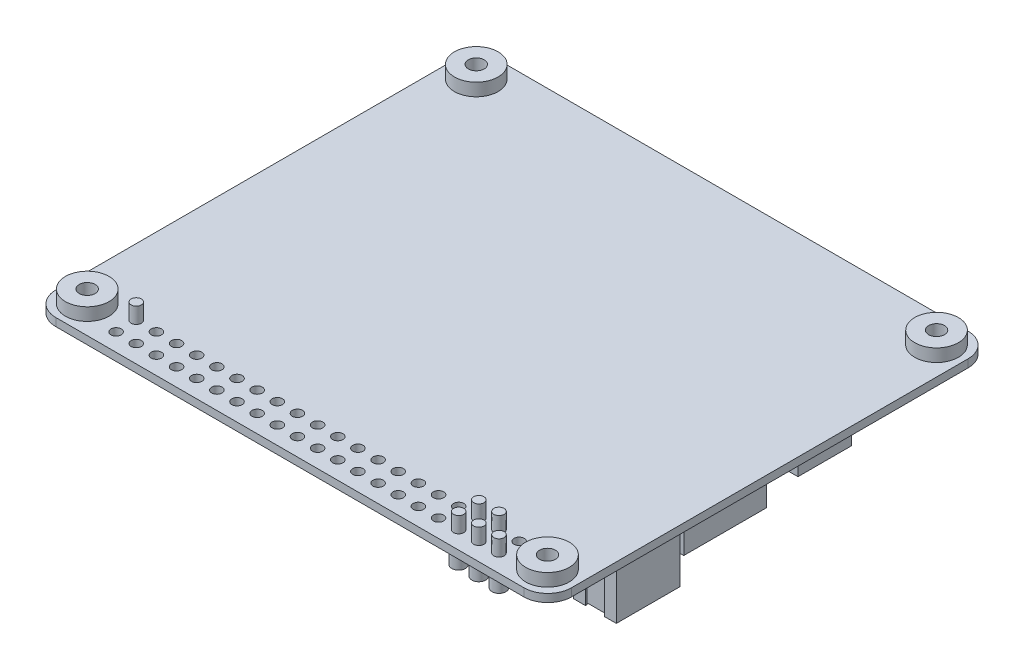
from build123d import *

# Parameters (mm, degrees)
SKETCH_1_W          = 65
SKETCH_1_H          = 56
EXTRUDE_1_DEPTH     = 1
FILLET_1_R          = 3
SKETCH_2_R          = 2.75
EXTRUDE_2_DEPTH     = 1.6
CUT_EXTRUDE_1_REACH = 4.6
SKETCH_3_R          = 1
SKETCH_4_W          = 9
SKETCH_4_H          = 7.4
EXTRUDE_3_DEPTH     = 3.2
SKETCH_5_W          = 9
SKETCH_5_H          = 3.2
EXTRUDE_4_DEPTH     = 1
FILLET_3_R          = 1
SKETCH_6_R          = 7
EXTRUDE_5_DEPTH     = 2
SKETCH_8_R          = 2
EXTRUDE_6_DEPTH     = 0.5
CUT_EXTRUDE_2_REACH = 5.2
SKETCH_9_R          = 1
CUT_EXTRUDE_3_DEPTH = 8
SKETCH_12_W         = 7.3
SKETCH_12_H         = 5.3
EXTRUDE_8_DEPTH     = 2.4
SKETCH_13_W         = 7.3
SKETCH_13_H         = 2.4
EXTRUDE_9_DEPTH     = 1
CHAMFER_1_SIZE      = 0.4
CHAMFER_2_SIZE      = 1
CUT_EXTRUDE_4_DEPTH = 2.4
CUT_EXTRUDE_5_DEPTH = 5.3
FILLET_4_R          = 0.2
SKETCH_19_W         = 5.4
SKETCH_19_H         = 8
EXTRUDE_13_DEPTH    = 6.22
CUT_EXTRUDE_6_DEPTH = 6.22
SKETCH_21_W         = 4.422179794
SKETCH_21_H         = 6.450695474
CUT_EXTRUDE_7_DEPTH = 5
SKETCH_22_W         = 0.5
SKETCH_22_H         = 0.5
EXTRUDE_14_DEPTH    = 5
CHAMFER_3_SIZE      = 0.1
SKETCH_26_R         = 0.65
CUT_EXTRUDE_8_DEPTH = 1
SKETCH_27_R         = 1.15
EXTRUDE_18_DEPTH    = 0.8
SKETCH_28_R         = 0.875
EXTRUDE_19_DEPTH    = 2
SKETCH_29_R         = 0.65
EXTRUDE_20_DEPTH    = 3
CUT_EXTRUDE_9_REACH = 58
SKETCH_31_W         = 11.624439254
SKETCH_31_H         = 10.421128159
SKETCH_31_W_2       = 3.292077523
SKETCH_31_H_2       = 3.337485489
SKETCH_31_W_3       = 4.813244378
SKETCH_31_H_3       = 2.792589899
SKETCH_31_W_4       = 7.492314363
SKETCH_31_H_4       = 6.76578691
SKETCH_31_W_5       = 1.377782595
SKETCH_31_H_5       = 1.831059243
SKETCH_31_W_6       = 1.754765108
SKETCH_31_H_6       = 0.839235487
SKETCH_31_W_7       = 2.098088716
SKETCH_31_H_7       = 1.322463405
SKETCH_31_W_8       = 1.068117891
SKETCH_31_W_9       = 1.3
SKETCH_31_H_8       = 2.146550116
SKETCH_31_W_10      = 0.991823756
SKETCH_31_H_9       = 1.449588567
SKETCH_31_W_11      = 3.166206607
SKETCH_31_H_10      = 3.280647809
SKETCH_31_W_12      = 0.842709574
SKETCH_31_H_11      = 1.605041461
SKETCH_31_W_13      = 4.765687667
SKETCH_31_H_12      = 2.32742886
SKETCH_31_W_14      = 4.69875361
SKETCH_31_W_15      = 3.470948669
SKETCH_31_H_13      = 2.726681948
SKETCH_31_H_14      = 2.690326189
SKETCH_31_W_16      = 3.780998968
SKETCH_31_H_15      = 4.835315988
SKETCH_31_W_17      = 1.810430141
SKETCH_31_H_16      = 3.134578542
SKETCH_31_W_18      = 1.494289172
SKETCH_31_H_17      = 1.867861464
SKETCH_31_W_19      = 1.698055876
SKETCH_31_H_18      = 0.882989056
SKETCH_31_W_20      = 1.444692437
SKETCH_31_H_19      = 1.765735201
SKETCH_31_W_21      = 0.917265039
SKETCH_31_H_20      = 1.757929107
SKETCH_31_W_22      = 0.894333413
SKETCH_31_W_23      = 1.017455488
SKETCH_31_H_21      = 1.832160457
SKETCH_31_W_24      = 0.86981355
SKETCH_31_W_25      = 0.925333564
SKETCH_31_W_26      = 1.024554729
SKETCH_31_W_27      = 1.805492983
SKETCH_31_H_22      = 1.114934251
SKETCH_31_W_28      = 1.647819888
SKETCH_31_H_23      = 0.929111875
SKETCH_31_W_29      = 1.746730327
SKETCH_31_H_24      = 1.022015741
SKETCH_31_H_25      = 0.906588082
SKETCH_31_W_30      = 1.276175138
SKETCH_31_H_26      = 1.850067253
SKETCH_31_W_31      = 1.114934251
SKETCH_31_W_32      = 1.709565851
SKETCH_31_W_33      = 0.966276351
SKETCH_31_H_27      = 1.486579001
SKETCH_31_W_34      = 1.7295443
SKETCH_31_H_28      = 0.811737531
SKETCH_31_W_35      = 0.86477215
SKETCH_31_H_29      = 1.634296795
SKETCH_31_W_36      = 0.8919474
SKETCH_31_W_37      = 0.881302432
SKETCH_31_H_30      = 1.750695372
SKETCH_31_W_38      = 1.560907951
SKETCH_31_H_31      = 0.96627635
SKETCH_31_W_39      = 1.686496858
SKETCH_31_H_32      = 3.315824332
SKETCH_31_W_40      = 1.770294977
SKETCH_31_H_33      = 0.973006575
SKETCH_31_W_41      = 3.160465266
SKETCH_31_H_34      = 1.922344852
SKETCH_31_W_42      = 0.955742073
SKETCH_31_H_35      = 1.672548629
SKETCH_31_W_43      = 0.945742571
SKETCH_31_W_44      = 0.953017514
SKETCH_31_W_45      = 0.951297926
SKETCH_31_W_46      = 2.624633637
SKETCH_31_H_36      = 3.49621009
EXTRUDE_21_DEPTH    = 0.6
SKETCH_32_W         = 11.624439254
SKETCH_32_H         = 10.421128159
EXTRUDE_22_DEPTH    = 3
SKETCH_33_W         = 7.492314363
SKETCH_33_H         = 6.76578691
EXTRUDE_23_DEPTH    = 2
SKETCH_34_W         = 4.765687667
SKETCH_34_H         = 2.32742886
SKETCH_34_W_2       = 4.69875361
EXTRUDE_24_DEPTH    = 1
SKETCH_35_W         = 2.4
SKETCH_35_H         = 1.007753986
EXTRUDE_25_DEPTH    = 0.8


with BuildPart() as part:
    # 草图1 → 凸台-拉伸1 (new body)
    with BuildSketch(Plane(origin=(0, 0, 0), x_dir=(1, 0, 0), z_dir=(0, 1, 0))):
        Rectangle(SKETCH_1_W, SKETCH_1_H)
    extrude(amount=EXTRUDE_1_DEPTH)

    # 圆角1
    fillet_1_edges = [part.edges().sort_by_distance(p)[0] for p in [
        (-32.5, 0.5, -28),
        (32.5, 0.5, -28),
        (32.5, 0.5, 28),
        (-32.5, 0.5, 28),
    ]]
    fillet(fillet_1_edges, radius=FILLET_1_R)

    # 草图2 → 凸台-拉伸2 (add)
    with BuildSketch(Plane(origin=(0, 1, 0), x_dir=(1, 0, 0), z_dir=(0, 1, 0))):
        with Locations((-29.03072734, 24.528667008)):
            Circle(SKETCH_2_R)
        with Locations((28.980840432, 24.528667008)):
            Circle(SKETCH_2_R)
        with Locations((-29.03072734, -24.506545585)):
            Circle(SKETCH_2_R)
        with Locations((28.980840432, -24.506545585)):
            Circle(SKETCH_2_R)
    extrude(amount=EXTRUDE_2_DEPTH)

    # 草图3 → 切除-拉伸1 (cut, up to next)
    with BuildSketch(Plane(origin=(0, 2.6, 0), x_dir=(1, 0, 0), z_dir=(0, 1, 0)), mode=Mode.PRIVATE) as cut_extrude_1_sk1:
        with Locations((-29.03072734, 24.528667008)):
            Circle(SKETCH_3_R)
    cut_extrude_1_tool1 = extrude(cut_extrude_1_sk1.sketch, amount=-CUT_EXTRUDE_1_REACH, mode=Mode.PRIVATE) & part.part
    add(cut_extrude_1_tool1.solids().sort_by_distance((-29.030727, 2.6, -24.528667))[0], mode=Mode.SUBTRACT)
    # 草图3 → 切除-拉伸1 (cut, up to next)
    with BuildSketch(Plane(origin=(0, 2.6, 0), x_dir=(1, 0, 0), z_dir=(0, 1, 0)), mode=Mode.PRIVATE) as cut_extrude_1_sk2:
        with Locations((28.980840432, 24.528667008)):
            Circle(SKETCH_3_R)
    cut_extrude_1_tool2 = extrude(cut_extrude_1_sk2.sketch, amount=-CUT_EXTRUDE_1_REACH, mode=Mode.PRIVATE) & part.part
    add(cut_extrude_1_tool2.solids().sort_by_distance((28.98084, 2.6, -24.528667))[0], mode=Mode.SUBTRACT)
    # 草图3 → 切除-拉伸1 (cut, up to next)
    with BuildSketch(Plane(origin=(0, 2.6, 0), x_dir=(1, 0, 0), z_dir=(0, 1, 0)), mode=Mode.PRIVATE) as cut_extrude_1_sk3:
        with Locations((-29.03072734, -24.506545585)):
            Circle(SKETCH_3_R)
    cut_extrude_1_tool3 = extrude(cut_extrude_1_sk3.sketch, amount=-CUT_EXTRUDE_1_REACH, mode=Mode.PRIVATE) & part.part
    add(cut_extrude_1_tool3.solids().sort_by_distance((-29.030727, 2.6, 24.506546))[0], mode=Mode.SUBTRACT)
    # 草图3 → 切除-拉伸1 (cut, up to next)
    with BuildSketch(Plane(origin=(0, 2.6, 0), x_dir=(1, 0, 0), z_dir=(0, 1, 0)), mode=Mode.PRIVATE) as cut_extrude_1_sk4:
        with Locations((28.980840432, -24.506545585)):
            Circle(SKETCH_3_R)
    cut_extrude_1_tool4 = extrude(cut_extrude_1_sk4.sketch, amount=-CUT_EXTRUDE_1_REACH, mode=Mode.PRIVATE) & part.part
    add(cut_extrude_1_tool4.solids().sort_by_distance((28.98084, 2.6, 24.506546))[0], mode=Mode.SUBTRACT)

    # 草图4 → 凸台-拉伸3 (add)
    with BuildSketch(Plane.XZ):
        with Locations((21, -24.3)):
            Rectangle(SKETCH_4_W, SKETCH_4_H)
    extrude(amount=EXTRUDE_3_DEPTH)

    # 草图5 → 凸台-拉伸4 (add)
    with BuildSketch(Plane(origin=(0, 0, -28), x_dir=(-1, 0, 0), z_dir=(0, 0, -1))):
        with Locations((-21, -1.6)):
            Rectangle(SKETCH_5_W, SKETCH_5_H)
    extrude(amount=EXTRUDE_4_DEPTH)

    # 圆角3
    fillet_3_edges = [part.edges().sort_by_distance(p)[0] for p in [
        (25.5, -3.2, -24.8),
        (16.5, -3.2, -24.8),
        (16.5, 0, -28.5),
        (25.5, 0, -28.5),
    ]]
    fillet(fillet_3_edges, radius=FILLET_3_R)

    # 草图6 → 凸台-拉伸5 (add)
    with BuildSketch(Plane.XZ):
        with Locations((-17.5, 0)):
            Circle(SKETCH_6_R)
    extrude(amount=EXTRUDE_5_DEPTH)

    # 草图8 → 凸台-拉伸6 (add)
    with BuildSketch(Plane.XZ):
        with Locations((28.980840432, 24.506545585)):
            Circle(SKETCH_8_R)
        with Locations((28.980840432, -24.528667008)):
            Circle(SKETCH_8_R)
        with Locations((-29.03072734, -24.528667008)):
            Circle(SKETCH_8_R)
        with Locations((-29.03072734, 24.506545585)):
            Circle(SKETCH_8_R)
    extrude(amount=EXTRUDE_6_DEPTH)

    # 草图9 → 切除-拉伸2 (cut, up to next)
    with BuildSketch(Plane(origin=(0, 0, 0), x_dir=(1, 0, 0), z_dir=(0, 1, 0)), mode=Mode.PRIVATE) as cut_extrude_2_sk1:
        with Locations((-29.03072734, 24.528667008)):
            Circle(SKETCH_9_R)
    cut_extrude_2_tool1 = extrude(cut_extrude_2_sk1.sketch, amount=-CUT_EXTRUDE_2_REACH, mode=Mode.PRIVATE) & part.part
    add(cut_extrude_2_tool1.solids().sort_by_distance((-29.030727, 0, -24.528667))[0], mode=Mode.SUBTRACT)
    # 草图9 → 切除-拉伸2 (cut, up to next)
    with BuildSketch(Plane(origin=(0, 0, 0), x_dir=(1, 0, 0), z_dir=(0, 1, 0)), mode=Mode.PRIVATE) as cut_extrude_2_sk2:
        with Locations((28.980840432, 24.528667008)):
            Circle(SKETCH_9_R)
    cut_extrude_2_tool2 = extrude(cut_extrude_2_sk2.sketch, amount=-CUT_EXTRUDE_2_REACH, mode=Mode.PRIVATE) & part.part
    add(cut_extrude_2_tool2.solids().sort_by_distance((28.98084, 0, -24.528667))[0], mode=Mode.SUBTRACT)
    # 草图9 → 切除-拉伸2 (cut, up to next)
    with BuildSketch(Plane(origin=(0, 0, 0), x_dir=(1, 0, 0), z_dir=(0, 1, 0)), mode=Mode.PRIVATE) as cut_extrude_2_sk3:
        with Locations((-29.03072734, -24.506545585)):
            Circle(SKETCH_9_R)
    cut_extrude_2_tool3 = extrude(cut_extrude_2_sk3.sketch, amount=-CUT_EXTRUDE_2_REACH, mode=Mode.PRIVATE) & part.part
    add(cut_extrude_2_tool3.solids().sort_by_distance((-29.030727, 0, 24.506546))[0], mode=Mode.SUBTRACT)
    # 草图9 → 切除-拉伸2 (cut, up to next)
    with BuildSketch(Plane(origin=(0, 0, 0), x_dir=(1, 0, 0), z_dir=(0, 1, 0)), mode=Mode.PRIVATE) as cut_extrude_2_sk4:
        with Locations((28.980840432, -24.506545585)):
            Circle(SKETCH_9_R)
    cut_extrude_2_tool4 = extrude(cut_extrude_2_sk4.sketch, amount=-CUT_EXTRUDE_2_REACH, mode=Mode.PRIVATE) & part.part
    add(cut_extrude_2_tool4.solids().sort_by_distance((28.98084, 0, 24.506546))[0], mode=Mode.SUBTRACT)

    # 草图10 → 切除-拉伸3 (cut)
    with BuildSketch(Plane(origin=(0, 0, -29), x_dir=(-1, 0, 0), z_dir=(0, 0, -1))):
        with BuildLine():
            Line((-17.5, -0.2), (-24.5, -0.2))
            ThreePointArc((-24.5, -0.2), (-25.065685425, -0.434314575), (-25.3, -1))
            Line((-25.3, -1), (-25.3, -2.2))
            ThreePointArc((-25.3, -2.2), (-25.065685425, -2.765685425), (-24.5, -3))
            Line((-24.5, -3), (-17.5, -3))
            ThreePointArc((-17.5, -3), (-16.934314575, -2.765685425), (-16.7, -2.2))
            Line((-16.7, -2.2), (-16.7, -1))
            ThreePointArc((-16.7, -1), (-16.934314575, -0.434314575), (-17.5, -0.2))
        make_face()
    extrude(amount=-CUT_EXTRUDE_3_DEPTH, mode=Mode.SUBTRACT)

    # 草图12 → 凸台-拉伸8 (add)
    with BuildSketch(Plane.XZ):
        with Locations((-20.25, -25.35)):
            Rectangle(SKETCH_12_W, SKETCH_12_H)
    extrude(amount=EXTRUDE_8_DEPTH)

    # 草图13 → 凸台-拉伸9 (add)
    with BuildSketch(Plane(origin=(0, 0, -28), x_dir=(-1, 0, 0), z_dir=(0, 0, -1))):
        with Locations((20.25, -1.2)):
            Rectangle(SKETCH_13_W, SKETCH_13_H)
    extrude(amount=EXTRUDE_9_DEPTH)

    # 倒角1
    chamfer_1_edges = [part.edges().sort_by_distance(p)[0] for p in [
        (-16.6, -2.4, -25.85),
        (-23.9, -2.4, -25.85),
    ]]
    chamfer(chamfer_1_edges, length=CHAMFER_1_SIZE)

    # 倒角2
    chamfer_2_edges = [part.edges().sort_by_distance(p)[0] for p in [
        (-23.9, 0, -28.5),
        (-16.6, 0, -28.5),
    ]]
    chamfer(chamfer_2_edges, length=CHAMFER_2_SIZE)

    # 草图14 → 切除-拉伸4 (cut)
    with BuildSketch(Plane(origin=(0, 0, -29), x_dir=(-1, 0, 0), z_dir=(0, 0, -1))):
        Polygon((22.817157288, -0.2), (17.682842712, -0.2), (16.8, -1.082842712), (16.8, -1.917157288), (17.082842712, -2.2), (23.417157288, -2.2), (23.7, -1.917157288), (23.7, -1.082842712), align=None)
    extrude(amount=-CUT_EXTRUDE_4_DEPTH, mode=Mode.SUBTRACT)

    # 草图17 → 切除-拉伸5 (cut)
    with BuildSketch(Plane(origin=(0, 0, -28), x_dir=(-1, 0, 0), z_dir=(0, 0, -1))):
        Polygon((23.9, -1), (23.9, 0), (22.9, 0), align=None)
        Polygon((16.6, 0), (17.6, 0), (16.6, -1), align=None)
    extrude(amount=-CUT_EXTRUDE_5_DEPTH, mode=Mode.SUBTRACT)

    # 圆角4
    fillet_4_edges = [part.edges().sort_by_distance(p)[0] for p in [
        (-24.5, -2, 0),
    ]]
    fillet(fillet_4_edges, radius=FILLET_4_R)

    # 草图19 → 凸台-拉伸13 (add)
    with BuildSketch(Plane.XZ):
        with Locations((29.3, 14.85)):
            Rectangle(SKETCH_19_W, SKETCH_19_H)
    extrude(amount=EXTRUDE_13_DEPTH)

    # 草图20 → 切除-拉伸6 (cut)
    with BuildSketch(Plane.XZ.offset(6.22)):
        Polygon((30.5, 18.85), (30.5, 18.65), (31.359940233, 18.65), (31.359940233, 18.45), (26.937760439, 18.45), (26.937760439, 18.65), (28.1, 18.65), (28.1, 18.85), align=None)
        Polygon((30.5, 10.85), (30.5, 11.05), (31.359940233, 11.05), (31.359940233, 11.25), (26.937760439, 11.25), (26.937760439, 11.05), (28.1, 11.05), (28.1, 10.85), align=None)
    extrude(amount=-CUT_EXTRUDE_6_DEPTH, mode=Mode.SUBTRACT)

    # 草图21 → 切除-拉伸7 (cut)
    with BuildSketch(Plane.XZ.offset(6.22)):
        with Locations((29.148850336, 14.85)):
            Rectangle(SKETCH_21_W, SKETCH_21_H)
    extrude(amount=-CUT_EXTRUDE_7_DEPTH, mode=Mode.SUBTRACT)

    # 草图22 → 凸台-拉伸14 (add)
    with BuildSketch(Plane.XZ.offset(1.22)):
        with Locations((29.324199983, 15.822120278)):
            Rectangle(SKETCH_22_W, SKETCH_22_H)
        with Locations((29.306578169, 14.081028721)):
            Rectangle(SKETCH_22_W, SKETCH_22_H)
    extrude(amount=EXTRUDE_14_DEPTH)

    # 倒角3
    chamfer_3_edges = [part.edges().sort_by_distance(p)[0] for p in [
        (29.074199983, -6.22, 15.822120278),
        (29.324199983, -6.22, 15.572120278),
        (29.574199983, -6.22, 15.822120278),
        (29.324199983, -6.22, 16.072120278),
        (29.056578169, -6.22, 14.081028721),
        (29.306578169, -6.22, 13.831028721),
        (29.556578169, -6.22, 14.081028721),
        (29.306578169, -6.22, 14.331028721),
    ]]
    chamfer(chamfer_3_edges, length=CHAMFER_3_SIZE)

    # 草图26 → 切除-拉伸8 (cut)
    with BuildSketch(Plane.XZ):
        with Locations((24.13, 25.77)):
            Circle(SKETCH_26_R)
        with Locations((21.59, 25.77)):
            Circle(SKETCH_26_R)
        with Locations((19.05, 25.77)):
            Circle(SKETCH_26_R)
        with Locations((16.51, 25.77)):
            Circle(SKETCH_26_R)
        with Locations((13.97, 25.77)):
            Circle(SKETCH_26_R)
        with Locations((11.43, 25.77)):
            Circle(SKETCH_26_R)
        with Locations((8.89, 25.77)):
            Circle(SKETCH_26_R)
        with Locations((6.35, 25.77)):
            Circle(SKETCH_26_R)
        with Locations((3.81, 25.77)):
            Circle(SKETCH_26_R)
        with Locations((1.27, 25.77)):
            Circle(SKETCH_26_R)
        with Locations((-1.27, 25.77)):
            Circle(SKETCH_26_R)
        with Locations((-3.81, 25.77)):
            Circle(SKETCH_26_R)
        with Locations((-6.35, 25.77)):
            Circle(SKETCH_26_R)
        with Locations((-8.89, 25.77)):
            Circle(SKETCH_26_R)
        with Locations((-11.43, 25.77)):
            Circle(SKETCH_26_R)
        with Locations((-13.97, 25.77)):
            Circle(SKETCH_26_R)
        with Locations((-16.51, 25.77)):
            Circle(SKETCH_26_R)
        with Locations((-19.05, 25.77)):
            Circle(SKETCH_26_R)
        with Locations((-21.59, 25.77)):
            Circle(SKETCH_26_R)
        with Locations((-24.13, 25.77)):
            Circle(SKETCH_26_R)
        with Locations((21.59, 23.23)):
            Circle(SKETCH_26_R)
        with Locations((19.05, 23.23)):
            Circle(SKETCH_26_R)
        with Locations((16.51, 23.23)):
            Circle(SKETCH_26_R)
        with Locations((13.97, 23.23)):
            Circle(SKETCH_26_R)
        with Locations((11.43, 23.23)):
            Circle(SKETCH_26_R)
        with Locations((8.89, 23.23)):
            Circle(SKETCH_26_R)
        with Locations((6.35, 23.23)):
            Circle(SKETCH_26_R)
        with Locations((3.81, 23.23)):
            Circle(SKETCH_26_R)
        with Locations((1.27, 23.23)):
            Circle(SKETCH_26_R)
        with Locations((-1.27, 23.23)):
            Circle(SKETCH_26_R)
        with Locations((-3.81, 23.23)):
            Circle(SKETCH_26_R)
        with Locations((-6.35, 23.23)):
            Circle(SKETCH_26_R)
        with Locations((-8.89, 23.23)):
            Circle(SKETCH_26_R)
        with Locations((-11.43, 23.23)):
            Circle(SKETCH_26_R)
        with Locations((-13.97, 23.23)):
            Circle(SKETCH_26_R)
        with Locations((-16.51, 23.23)):
            Circle(SKETCH_26_R)
        with Locations((-19.05, 23.23)):
            Circle(SKETCH_26_R)
        with Locations((-21.59, 23.23)):
            Circle(SKETCH_26_R)
        with Locations((-24.13, 23.23)):
            Circle(SKETCH_26_R)
        with Locations((24.13, 23.23)):
            Circle(SKETCH_26_R)
    extrude(amount=-CUT_EXTRUDE_8_DEPTH, mode=Mode.SUBTRACT)

    # 草图27 → 凸台-拉伸18 (add)
    with BuildSketch(Plane.XZ):
        with Locations((24.13, 25.77)):
            Circle(SKETCH_27_R)
        with Locations((21.59, 25.77)):
            Circle(SKETCH_27_R)
        with Locations((21.59, 23.23)):
            Circle(SKETCH_27_R)
        with Locations((19.05, 25.77)):
            Circle(SKETCH_27_R)
        with Locations((19.05, 23.23)):
            Circle(SKETCH_27_R)
        with Locations((13.97, 23.23)):
            Circle(SKETCH_27_R)
    extrude(amount=EXTRUDE_18_DEPTH)

    # 草图28 → 凸台-拉伸19 (add)
    with BuildSketch(Plane(origin=(0, -0.8, 0), x_dir=(-1, 0, 0), z_dir=(0, -1, 0))):
        with Locations((-24.13, -25.77)):
            Circle(SKETCH_28_R)
        with Locations((-21.59, -25.77)):
            Circle(SKETCH_28_R)
        with Locations((-19.05, -23.23)):
            Circle(SKETCH_28_R)
        with Locations((-21.59, -23.23)):
            Circle(SKETCH_28_R)
        with Locations((-19.05, -25.77)):
            Circle(SKETCH_28_R)
        with Locations((-13.97, -23.23)):
            Circle(SKETCH_28_R)
    extrude(amount=EXTRUDE_19_DEPTH)

    # 草图29 → 凸台-拉伸20 (add)
    with BuildSketch(Plane(origin=(0, 0, 0), x_dir=(1, 0, 0), z_dir=(0, 1, 0))):
        with Locations((19.05, -23.23)):
            Circle(SKETCH_29_R)
        with Locations((19.05, -25.77)):
            Circle(SKETCH_29_R)
        with Locations((21.59, -23.23)):
            Circle(SKETCH_29_R)
        with Locations((21.59, -25.77)):
            Circle(SKETCH_29_R)
        with Locations((24.13, -25.77)):
            Circle(SKETCH_29_R)
        with Locations((-24.13, -23.23)):
            Circle(SKETCH_29_R)
    extrude(amount=EXTRUDE_20_DEPTH)

    # 草图30 → 切除-拉伸9 (cut, up to next)
    with BuildSketch(Plane(origin=(0, 0, -28), x_dir=(-1, 0, 0), z_dir=(0, 0, -1)), mode=Mode.PRIVATE) as cut_extrude_9_sk1:
        with BuildLine():
            Line((-16.5, 0), (-17.5, 0))
            ThreePointArc((-17.5, 0), (-16.792893219, -0.292893219), (-16.5, -1))
            Line((-16.5, -1), (-16.5, 0))
        make_face()
    cut_extrude_9_tool1 = extrude(cut_extrude_9_sk1.sketch, amount=-CUT_EXTRUDE_9_REACH, mode=Mode.PRIVATE) & part.part
    add(cut_extrude_9_tool1.solids().sort_by_distance((16.723368, -0.223368, -28))[0], mode=Mode.SUBTRACT)
    # 草图30 → 切除-拉伸9 (cut, up to next)
    with BuildSketch(Plane(origin=(0, 0, -28), x_dir=(-1, 0, 0), z_dir=(0, 0, -1)), mode=Mode.PRIVATE) as cut_extrude_9_sk2:
        with BuildLine():
            Line((-25.5, 0), (-24.5, 0))
            ThreePointArc((-24.5, 0), (-25.207106781, -0.292893219), (-25.5, -1))
            Line((-25.5, -1), (-25.5, 0))
        make_face()
    cut_extrude_9_tool2 = extrude(cut_extrude_9_sk2.sketch, amount=-CUT_EXTRUDE_9_REACH, mode=Mode.PRIVATE) & part.part
    add(cut_extrude_9_tool2.solids().sort_by_distance((25.276632, -0.223368, -28))[0], mode=Mode.SUBTRACT)

    # 草图31 → 凸台-拉伸21 (add)
    with BuildSketch(Plane.XZ):
        with Locations((25.646763293, 4.599644195)):
            Rectangle(SKETCH_31_W, SKETCH_31_H)
        with Locations((29.812944159, -2.847262203)):
            Rectangle(SKETCH_31_W_2, SKETCH_31_H_2)
        with Locations((24.738603976, -2.801854237)):
            Rectangle(SKETCH_31_W_3, SKETCH_31_H_3)
        with Locations((27.304154045, -8.375682043)):
            Rectangle(SKETCH_31_W_4, SKETCH_31_H_4)
        with Locations((30.770091623, -14.20397661)):
            Rectangle(SKETCH_31_W_5, SKETCH_31_H_5)
        with Locations((28.517170555, -12.639946841)):
            Rectangle(SKETCH_31_W_6, SKETCH_31_H_6)
        with Locations((24.073037185, -19.938768298)):
            Rectangle(SKETCH_31_W_7, SKETCH_31_H_7)
        with Locations((21.26922772, -19.938768298)):
            Rectangle(SKETCH_31_W_8, SKETCH_31_H_7)
        with Locations((-5.559467443, -25.671993106)):
            Rectangle(SKETCH_31_W_9, SKETCH_31_H_8)
        with Locations((19.743345017, -19.938768298)):
            Rectangle(SKETCH_31_W_10, SKETCH_31_H_7)
        with Locations((24.073037185, -17.789800961)):
            Rectangle(SKETCH_31_W_7, SKETCH_31_H_9)
        with Locations((19.686124416, -14.699888489)):
            Rectangle(SKETCH_31_W_11, SKETCH_31_H_10)
        with Locations((18.826078352, -1.413440616)):
            Rectangle(SKETCH_31_W_12, SKETCH_31_H_11)
        with Locations((10.775928968, -26.136757966)):
            Rectangle(SKETCH_31_W_13, SKETCH_31_H_12)
        with Locations((2.349376805, -26.136757966)):
            Rectangle(SKETCH_31_W_14, SKETCH_31_H_12)
        with Locations((6.6576108, 14.612412855)):
            Rectangle(SKETCH_31_W_15, SKETCH_31_H_13)
        with Locations((6.6576108, 10.376966896)):
            Rectangle(SKETCH_31_W_15, SKETCH_31_H_14)
        with Locations((7.79424145, 3.887463859)):
            Rectangle(SKETCH_31_W_16, SKETCH_31_H_15)
        with Locations((-2.462390408, -25.733183125)):
            Rectangle(SKETCH_31_W_17, SKETCH_31_H_16)
        with Locations((-7.651781686, -25.671993106)):
            Rectangle(SKETCH_31_W_9, SKETCH_31_H_8)
        with Locations((-9.797265884, -25.671993106)):
            Rectangle(SKETCH_31_W_9, SKETCH_31_H_8)
        with Locations((-11.862545065, -25.671993106)):
            Rectangle(SKETCH_31_W_9, SKETCH_31_H_8)
        with Locations((-13.907772992, -25.671993106)):
            Rectangle(SKETCH_31_W_9, SKETCH_31_H_8)
        with Locations((-0.092682317, -18.749521898)):
            Rectangle(SKETCH_31_W_18, SKETCH_31_H_17)
        with Locations((-10.824395456, -18.528774634)):
            Rectangle(SKETCH_31_W_19, SKETCH_31_H_18)
        with Locations((-1.945628233, 2.711116956)):
            Rectangle(SKETCH_31_W_20, SKETCH_31_H_19)
        with Locations((-2.713837703, -3.637040393)):
            Rectangle(SKETCH_31_W_21, SKETCH_31_H_20)
        with Locations((-5.08726099, -3.637040393)):
            Rectangle(SKETCH_31_W_22, SKETCH_31_H_20)
        with Locations((-6.718195187, -4.811619016)):
            Rectangle(SKETCH_31_W_23, SKETCH_31_H_21)
        with Locations((-8.068976474, -4.811619016)):
            Rectangle(SKETCH_31_W_24, SKETCH_31_H_21)
        with Locations((-9.355190128, -4.811619016)):
            Rectangle(SKETCH_31_W_25, SKETCH_31_H_21)
        with Locations((-10.7002677, -4.811619016)):
            Rectangle(SKETCH_31_W_26, SKETCH_31_H_21)
        with Locations((11.67867546, 8.813731241)):
            Rectangle(SKETCH_31_W_27, SKETCH_31_H_22)
        with Locations((10.854765515, 7.420063427)):
            Rectangle(SKETCH_31_W_28, SKETCH_31_H_23)
        with Locations((11.275865485, 5.794113983)):
            Rectangle(SKETCH_31_W_29, SKETCH_31_H_24)
        with Locations((11.275865485, 1.016511824)):
            Rectangle(SKETCH_31_W_29, SKETCH_31_H_25)
        with Locations((11.04058789, -1.29092772)):
            Rectangle(SKETCH_31_W_30, SKETCH_31_H_26)
        with Locations((9.473388445, -1.29092772)):
            Rectangle(SKETCH_31_W_31, SKETCH_31_H_26)
        with Locations((8.061138395, 7.420063427)):
            Rectangle(SKETCH_31_W_32, SKETCH_31_H_23)
        with Locations((6.091421218, -0.180071718)):
            Rectangle(SKETCH_31_W_33, SKETCH_31_H_27)
        with Locations((4.057364315, 1.422380589)):
            Rectangle(SKETCH_31_W_34, SKETCH_31_H_28)
        with Locations((4.48975039, -0.588410889)):
            Rectangle(SKETCH_31_W_35, SKETCH_31_H_29)
        with Locations((3.192592165, -0.588410889)):
            Rectangle(SKETCH_31_W_36, SKETCH_31_H_29)
        with Locations((4.934805842, 3.938827149)):
            Rectangle(SKETCH_31_W_37, SKETCH_31_H_30)
        with Locations((2.41213819, 2.83025076)):
            Rectangle(SKETCH_31_W_38, SKETCH_31_H_31)
        with Locations((-27.279776291, 16.473030119)):
            Rectangle(SKETCH_31_W_39, SKETCH_31_H_32)
        with Locations((-15.759707838, -12.706832385)):
            Rectangle(SKETCH_31_W_40, SKETCH_31_H_33)
        with Locations((-15.781429248, -15.577260503)):
            Rectangle(SKETCH_31_W_41, SKETCH_31_H_34)
        with Locations((-18.32826466, -17.526757119)):
            Rectangle(SKETCH_31_W_42, SKETCH_31_H_35)
        with Locations((-19.938154066, -17.526757119)):
            Rectangle(SKETCH_31_W_43, SKETCH_31_H_35)
        with Locations((-21.47680448, -17.526757119)):
            Rectangle(SKETCH_31_W_44, SKETCH_31_H_35)
        with Locations((-22.917565981, -17.526757119)):
            Rectangle(SKETCH_31_W_45, SKETCH_31_H_35)
        with Locations((-20.876075422, -13.154234718)):
            Rectangle(SKETCH_31_W_46, SKETCH_31_H_36)
    extrude(amount=EXTRUDE_21_DEPTH)

    # 草图32 → 凸台-拉伸22 (add)
    with BuildSketch(Plane.XZ.offset(0.6)):
        with Locations((25.646763293, 4.599644195)):
            Rectangle(SKETCH_32_W, SKETCH_32_H)
    extrude(amount=EXTRUDE_22_DEPTH)

    # 草图33 → 凸台-拉伸23 (add)
    with BuildSketch(Plane.XZ.offset(0.6)):
        with Locations((27.304154045, -8.375682043)):
            Rectangle(SKETCH_33_W, SKETCH_33_H)
    extrude(amount=EXTRUDE_23_DEPTH)

    # 草图34 → 凸台-拉伸24 (add)
    with BuildSketch(Plane.XZ.offset(0.6)):
        with Locations((10.775928968, -26.136757966)):
            Rectangle(SKETCH_34_W, SKETCH_34_H)
        with Locations((2.349376805, -26.136757966)):
            Rectangle(SKETCH_34_W_2, SKETCH_34_H)
    extrude(amount=EXTRUDE_24_DEPTH)

    # 草图35 → 凸台-拉伸25 (add)
    with BuildSketch(Plane(origin=(0, 0, -27.300472396), x_dir=(-1, 0, 0), z_dir=(0, 0, -1))):
        with Locations((-2.349376805, -0.8)):
            Rectangle(SKETCH_35_W, SKETCH_35_H)
        with Locations((-10.775928968, -0.8)):
            Rectangle(SKETCH_35_W, SKETCH_35_H)
    extrude(amount=EXTRUDE_25_DEPTH)


solid = part.part
